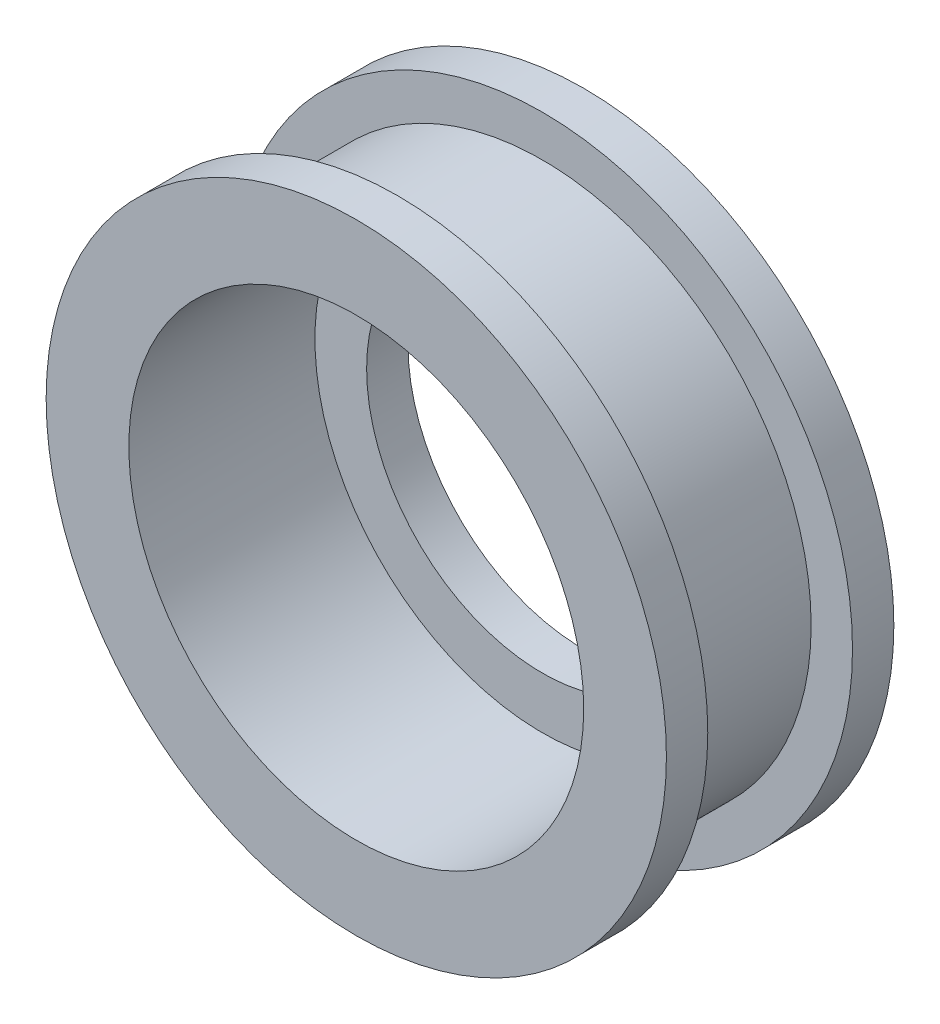
from build123d import *

# Parameters (mm, degrees)
CROQUIS1_R              = 15
CROQUIS1_R_2            = 8.5
SALIENTE_EXTRUIR1_DEPTH = 2
CROQUIS2_R              = 13
CROQUIS2_R_2            = 11
SALIENTE_EXTRUIR2_DEPTH = 7
CROQUIS3_R              = 15
CROQUIS3_R_2            = 11
SALIENTE_EXTRUIR3_DEPTH = 2


with BuildPart() as part:
    # Croquis1 → Saliente-Extruir1 (new body)
    with BuildSketch(Plane.XY):
        Circle(CROQUIS1_R)
        Circle(CROQUIS1_R_2, mode=Mode.SUBTRACT)
    extrude(amount=SALIENTE_EXTRUIR1_DEPTH)

    # Croquis2 → Saliente-Extruir2 (add)
    with BuildSketch(Plane.XY.offset(2)):
        Circle(CROQUIS2_R)
        Circle(CROQUIS2_R_2, mode=Mode.SUBTRACT)
    extrude(amount=SALIENTE_EXTRUIR2_DEPTH)

    # Croquis3 → Saliente-Extruir3 (add)
    with BuildSketch(Plane.XY.offset(9)):
        Circle(CROQUIS3_R)
        Circle(CROQUIS3_R_2, mode=Mode.SUBTRACT)
    extrude(amount=SALIENTE_EXTRUIR3_DEPTH)


solid = part.part
